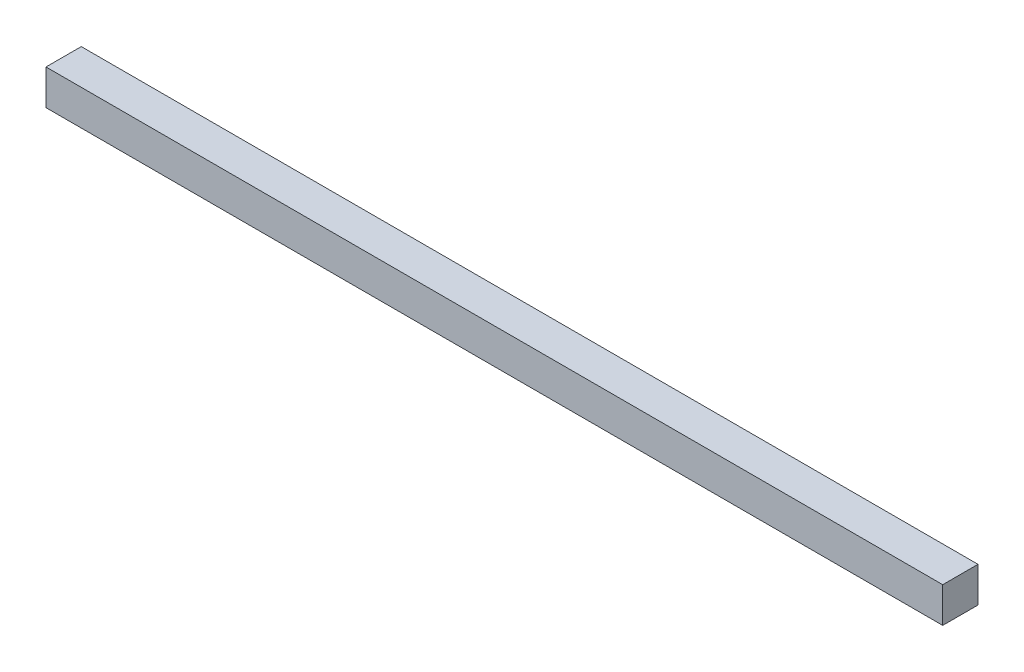
from build123d import *

# Parameters (mm, degrees)
SKETCH1_W           = 76.25
SKETCH1_H           = 3
BOSS_EXTRUDE1_DEPTH = 3


with BuildPart() as part:
    # Sketch1 → Boss-Extrude1 (new body)
    with BuildSketch(Plane.XY):
        with Locations((38.125, 1.5)):
            Rectangle(SKETCH1_W, SKETCH1_H)
    extrude(amount=BOSS_EXTRUDE1_DEPTH)


solid = part.part
